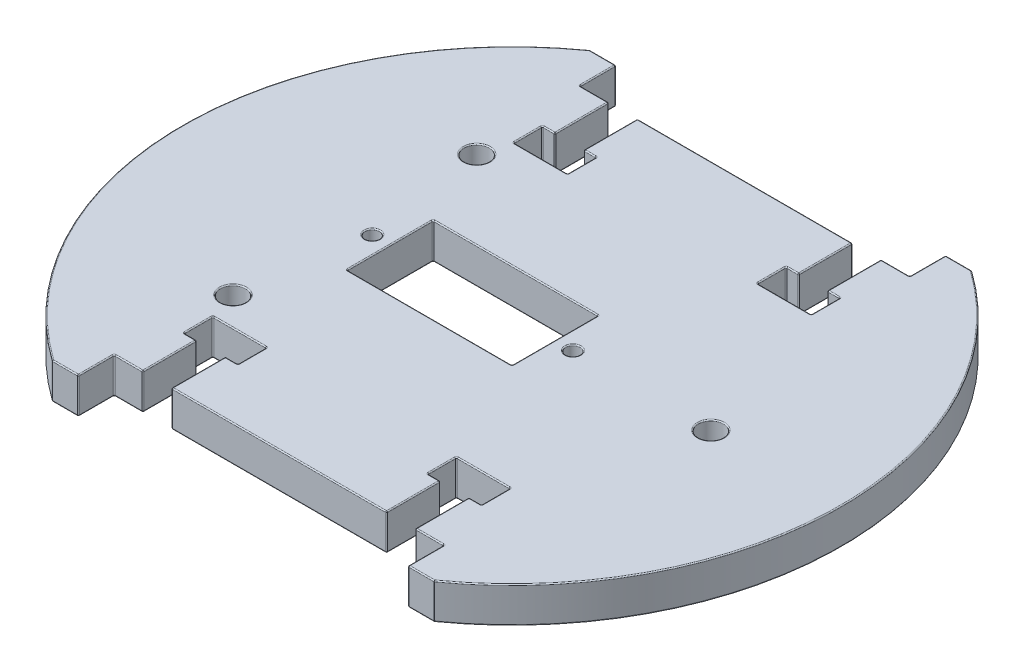
from build123d import *

# Parameters (mm, degrees)
SKETCH1_R           = 1
SKETCH1_R_2         = 1.75
SKETCH1_W           = 23
SKETCH1_H           = 12
BOSS_EXTRUDE1_DEPTH = 5
SKETCH2_W           = 4
SKETCH2_H           = 7.5
SKETCH2_W_2         = 7.5
SKETCH2_H_2         = 4
CUT_EXTRUDE1_DEPTH  = 6
FILLET1_R           = 0.15


with BuildPart() as part:
    # Sketch1 → Boss-Extrude1 (new body)
    with BuildSketch(Plane(origin=(0, 0, 0), x_dir=(1, 0, 0), z_dir=(0, 1, 0))):
        with BuildLine():
            Line((-26.64113361, 37.5), (-23, 37.5))
            Line((-23, 37.5), (-23, 32.5))
            Line((-23, 32.5), (23, 32.5))
            Line((23, 32.5), (23, 37.5))
            Line((23, 37.5), (26.64113361, 37.5))
            ThreePointArc((26.64113361, 37.5), (46, 0), (26.64113361, -37.5))
            Line((26.64113361, -37.5), (23, -37.5))
            Line((23, -37.5), (23, -32.5))
            Line((23, -32.5), (-23, -32.5))
            Line((-23, -32.5), (-23, -37.5))
            Line((-23, -37.5), (-26.64113361, -37.5))
            ThreePointArc((-26.64113361, -37.5), (-46, 0), (-26.64113361, 37.5))
        make_face()
        with Locations((-19.5, 0)):
            Circle(SKETCH1_R, mode=Mode.SUBTRACT)
        with Locations((8.5, 0)):
            Circle(SKETCH1_R, mode=Mode.SUBTRACT)
        with Locations((-21.93, 17)):
            Circle(SKETCH1_R_2, mode=Mode.SUBTRACT)
        with Locations((-21.93, -17)):
            Circle(SKETCH1_R_2, mode=Mode.SUBTRACT)
        with Locations((27.75, 0)):
            Circle(SKETCH1_R_2, mode=Mode.SUBTRACT)
        with Locations((-5.5, 0)):
            Rectangle(SKETCH1_W, SKETCH1_H, mode=Mode.SUBTRACT)
    extrude(amount=BOSS_EXTRUDE1_DEPTH)

    # Sketch2 → Cut-Extrude1 (cut, through all)
    with BuildSketch(Plane(origin=(0, 5, 0), x_dir=(1, 0, 0), z_dir=(0, 1, 0))):
        with Locations((-17, 28.75)):
            Rectangle(SKETCH2_W, SKETCH2_H)
        with Locations((-17, 23)):
            Rectangle(SKETCH2_W_2, SKETCH2_H_2)
        with Locations((17, 23)):
            Rectangle(SKETCH2_W_2, SKETCH2_H_2)
        with Locations((17, 28.75)):
            Rectangle(SKETCH2_W, SKETCH2_H)
        with Locations((17, -28.75)):
            Rectangle(SKETCH2_W, SKETCH2_H)
        with Locations((17, -23)):
            Rectangle(SKETCH2_W_2, SKETCH2_H_2)
        with Locations((-17, -23)):
            Rectangle(SKETCH2_W_2, SKETCH2_H_2)
        with Locations((-17, -28.75)):
            Rectangle(SKETCH2_W, SKETCH2_H)
    extrude(amount=-CUT_EXTRUDE1_DEPTH, mode=Mode.SUBTRACT)

    # Fillet1
    fillet1_edges = [part.edges().sort_by_distance(p)[0] for p in [
        (-19, 5, -28.75),
        (-19, 2.5, -25),
        (-19, 2.5, -32.5),
        (-15, 0, -28.75),
        (-15, 2.5, -32.5),
        (-14.125, 0, -25),
        (-20.75, 0, -23),
        (-19.875, 0, -25),
        (-19, 0, -28.75),
        (-17, 5, -21),
        (-13.25, 5, -23),
        (-15, 5, -28.75),
        (-17, 0, -21),
        (-13.25, 2.5, -21),
        (-20.75, 5, -23),
        (-20.75, 2.5, -21),
        (-13.25, 0, -23),
        (-13.25, 2.5, -25),
        (-15, 2.5, -25),
        (-14.125, 5, -25),
        (-20.75, 2.5, -25),
        (-19.875, 5, -25),
        (19, 5, 28.75),
        (19, 2.5, 25),
        (19, 2.5, 32.5),
        (15, 0, 28.75),
        (15, 2.5, 32.5),
        (14.125, 0, 25),
        (20.75, 0, 23),
        (19.875, 0, 25),
        (19, 0, 28.75),
        (17, 5, 21),
        (13.25, 5, 23),
        (15, 5, 28.75),
        (17, 0, 21),
        (13.25, 2.5, 21),
        (20.75, 5, 23),
        (20.75, 2.5, 21),
        (13.25, 0, 23),
        (13.25, 2.5, 25),
        (15, 2.5, 25),
        (14.125, 5, 25),
        (20.75, 2.5, 25),
        (19.875, 5, 25),
        (-24.820566805, 0, -37.5),
        (-23, 0, -35),
        (-17, 5, 21),
        (-20.75, 2.5, 21),
        (-13.25, 5, 23),
        (-13.25, 2.5, 21),
        (-20.75, 0, 23),
        (-20.75, 2.5, 25),
        (-20.75, 5, 23),
        (-19.875, 5, 25),
        (-19, 5, 28.75),
        (-14.125, 5, 25),
        (-17, 0, 21),
        (-13.25, 0, 23),
        (-15, 0, 28.75),
        (-19.875, 0, 25),
        (-23, 5, 35),
        (21, 0, -32.5),
        (-19, 2.5, 25),
        (-14.125, 0, 25),
        (-13.25, 2.5, 25),
        (-15, 2.5, 32.5),
        (-19, 0, 28.75),
        (-19, 2.5, 32.5),
        (-15, 5, 28.75),
        (-15, 2.5, 25),
        (23, 0, -35),
        (15, 5, -28.75),
        (15, 2.5, -25),
        (24.820566805, 0, -37.5),
        (15, 2.5, -32.5),
        (19, 0, -28.75),
        (19, 2.5, -32.5),
        (17, 0, -21),
        (13.25, 0, -23),
        (15, 0, -28.75),
        (14.125, 5, -25),
        (20.75, 5, -23),
        (19.875, 5, -25),
        (19, 5, -28.75),
        (17, 5, -21),
        (20.75, 2.5, -21),
        (13.25, 5, -23),
        (13.25, 2.5, -21),
        (20.75, 0, -23),
        (46, 0, 0),
        (20.75, 2.5, -25),
        (19.875, 0, -25),
        (19, 2.5, -25),
        (14.125, 0, -25),
        (13.25, 2.5, -25),
        (24.820566805, 0, 37.5),
        (23, 0, 35),
        (-21, 0, 32.5),
        (-23, 0, 35),
        (-24.820566805, 0, 37.5),
        (-46, 0, 0),
        (-21, 5, 32.5),
        (-26.64113361, 2.5, -37.5),
        (-23, 2.5, -37.5),
        (-23, 2.5, -32.5),
        (23, 5, 35),
        (23, 2.5, -32.5),
        (23, 2.5, -37.5),
        (26.64113361, 2.5, -37.5),
        (26.64113361, 2.5, 37.5),
        (23, 2.5, 37.5),
        (23, 2.5, 32.5),
        (-23, 2.5, 32.5),
        (-23, 2.5, 37.5),
        (-26.64113361, 2.5, 37.5),
        (24.820566805, 5, 37.5),
        (46, 5, 0),
        (24.820566805, 5, -37.5),
        (6, 0, 0),
        (6, 2.5, 6),
        (-5.5, 0, -6),
        (6, 2.5, -6),
        (-17, 0, 0),
        (-17, 2.5, -6),
        (-5.5, 0, 6),
        (-17, 2.5, 6),
        (6, 5, 0),
        (-5.5, 5, -6),
        (-17, 5, 0),
        (-5.5, 5, 6),
        (23, 5, -35),
        (21, 5, -32.5),
        (7.5, 0, 0),
        (7.5, 5, 0),
        (-23, 5, -35),
        (-20.5, 0, 0),
        (-20.5, 5, 0),
        (-24.820566805, 5, -37.5),
        (-46, 5, 0),
        (-23.68, 0, 17),
        (-23.68, 5, 17),
        (26, 0, 0),
        (26, 5, 0),
        (-23.68, 0, -17),
        (-23.68, 5, -17),
        (0, 0, -32.5),
        (-21, 0, -32.5),
        (0, 5, -32.5),
        (-21, 5, -32.5),
        (0, 0, 32.5),
        (21, 0, 32.5),
        (0, 5, 32.5),
        (21, 5, 32.5),
        (-24.820566805, 5, 37.5),
    ]]
    fillet(fillet1_edges, radius=FILLET1_R)


solid = part.part
